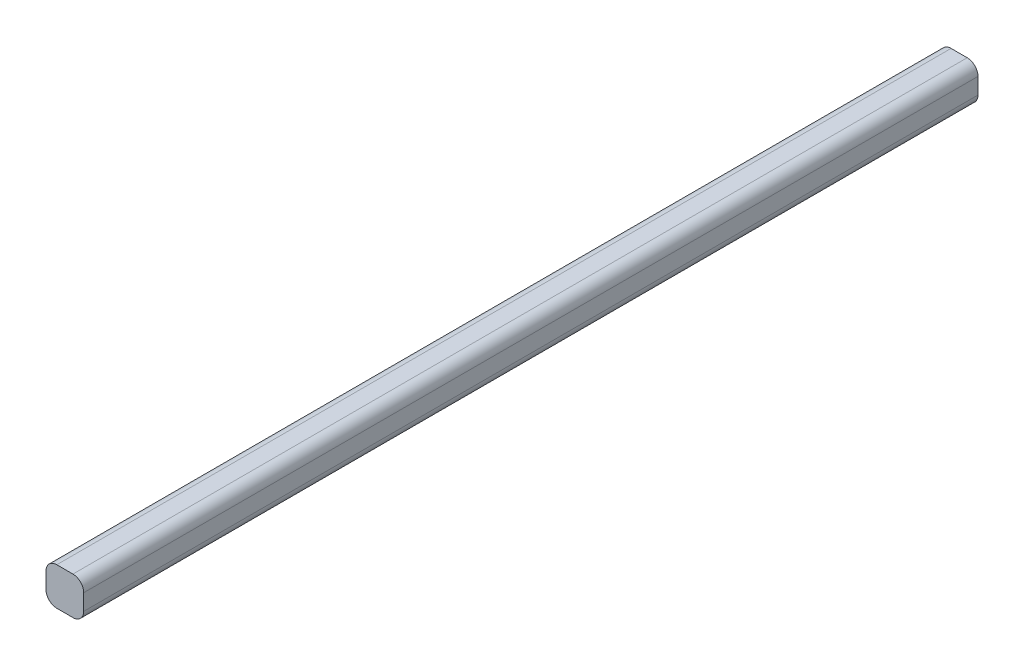
from build123d import *

# Parameters (mm, degrees)
ESBO_O1_W                = 35
ESBO_O1_H                = 35
RESSALTO_EXTRUS_O1_DEPTH = 830
FILETE1_R                = 10


with BuildPart() as part:
    # Esboço1 → Ressalto-extrusão1 (new body)
    with BuildSketch(Plane.XY):
        with Locations((17.5, 17.5)):
            Rectangle(ESBO_O1_W, ESBO_O1_H)
    extrude(amount=RESSALTO_EXTRUS_O1_DEPTH)

    # Filete1
    filete1_edges = [part.edges().sort_by_distance(p)[0] for p in [
        (0, 35, 415),
        (35, 35, 415),
        (35, 0, 415),
        (0, 0, 415),
    ]]
    fillet(filete1_edges, radius=FILETE1_R)


solid = part.part
